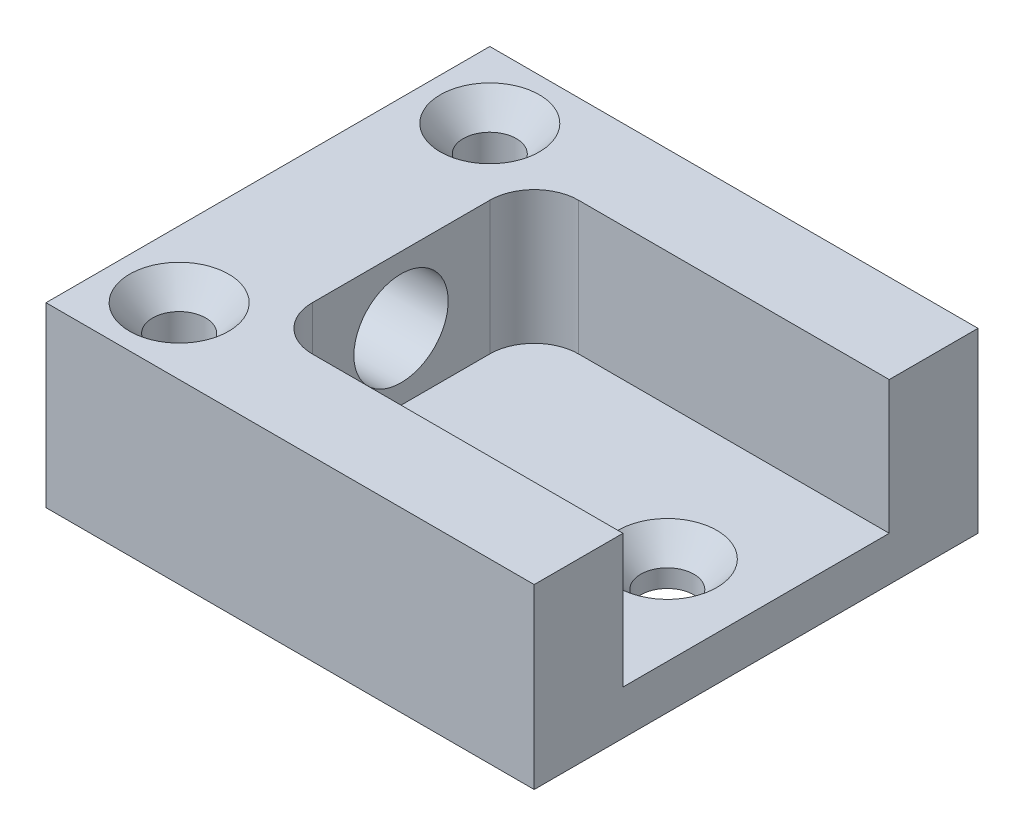
from build123d import *

# Parameters (mm, degrees)
BOSS_EXTRUDE1_DEPTH                            = 12.7
SKETCH2_W                                      = 25.4
SKETCH2_H                                      = 19.05
BOSS_EXTRUDE2_DEPTH                            = 3.175
FILLET1_R                                      = 3.175
F_17_64_0_26563_DIAMETER_HOLE1_D               = 6.747002
CSK_FOR_6_FLAT_HEAD_MACHINE_SCREW1_D           = 3.7973
CSK_FOR_6_FLAT_HEAD_MACHINE_SCREW1_DEPTH       = 16.51
CSK_FOR_6_FLAT_HEAD_MACHINE_SCREW1_CSINK_D     = 7.0866
CSK_FOR_6_FLAT_HEAD_MACHINE_SCREW1_CSINK_ANGLE = 82
CSK_FOR_6_FLAT_HEAD_MACHINE_SCREW1_TIP         = 1.140824014
CSK_FOR_6_FLAT_HEAD_MACHINE_SCREW2_D           = 3.7973
CSK_FOR_6_FLAT_HEAD_MACHINE_SCREW2_DEPTH       = 16.51
CSK_FOR_6_FLAT_HEAD_MACHINE_SCREW2_CSINK_D     = 7.0866
CSK_FOR_6_FLAT_HEAD_MACHINE_SCREW2_CSINK_ANGLE = 82
CSK_FOR_6_FLAT_HEAD_MACHINE_SCREW2_TIP         = 1.140824014


with BuildPart() as part:
    # Sketch1 → Boss-Extrude1 (new body)
    with BuildSketch(Plane(origin=(0, 0, 0), x_dir=(1, 0, 0), z_dir=(0, 1, 0))):
        Polygon((0, 15.875), (0, -15.875), (34.925, -15.875), (34.925, -9.525), (9.525, -9.525), (9.525, 9.525), (34.925, 9.525), (34.925, 15.875), align=None)
    extrude(amount=BOSS_EXTRUDE1_DEPTH)

    # Sketch2 → Boss-Extrude2 (add)
    with BuildSketch(Plane.XZ):
        with Locations((22.225, 0)):
            Rectangle(SKETCH2_W, SKETCH2_H)
    extrude(amount=-BOSS_EXTRUDE2_DEPTH)

    # Fillet1
    fillet1_edges = [part.edges().sort_by_distance(p)[0] for p in [
        (9.525, 7.9375, -9.525),
        (9.525, 7.9375, 9.525),
    ]]
    fillet(fillet1_edges, radius=FILLET1_R)

    # 17/64 (0.26563) Diameter Hole1 (through all)
    with Locations(Plane.ZY):
        with Locations((0, 7.9375)):
            Hole(F_17_64_0_26563_DIAMETER_HOLE1_D / 2)

    # CSK for #6 Flat Head Machine Screw1
    with Locations(Plane(origin=(0, 12.7, 0), x_dir=(1, 0, 0), z_dir=(0, 1, 0))):
        with Locations((4.7625, -11.1125), (4.7625, 11.1125)):
            CounterSinkHole(CSK_FOR_6_FLAT_HEAD_MACHINE_SCREW1_D / 2, CSK_FOR_6_FLAT_HEAD_MACHINE_SCREW1_CSINK_D / 2, depth=CSK_FOR_6_FLAT_HEAD_MACHINE_SCREW1_DEPTH, counter_sink_angle=CSK_FOR_6_FLAT_HEAD_MACHINE_SCREW1_CSINK_ANGLE)
            with Locations((0, 0, -(CSK_FOR_6_FLAT_HEAD_MACHINE_SCREW1_DEPTH + CSK_FOR_6_FLAT_HEAD_MACHINE_SCREW1_TIP / 2))):  # 118° drill point
                Cone(0, CSK_FOR_6_FLAT_HEAD_MACHINE_SCREW1_D / 2, CSK_FOR_6_FLAT_HEAD_MACHINE_SCREW1_TIP, mode=Mode.SUBTRACT)

    # CSK for #6 Flat Head Machine Screw2
    with Locations(Plane(origin=(0, 3.175, 0), x_dir=(1, 0, 0), z_dir=(0, 1, 0))):
        with Locations((28.575, 0)):
            CounterSinkHole(CSK_FOR_6_FLAT_HEAD_MACHINE_SCREW2_D / 2, CSK_FOR_6_FLAT_HEAD_MACHINE_SCREW2_CSINK_D / 2, depth=CSK_FOR_6_FLAT_HEAD_MACHINE_SCREW2_DEPTH, counter_sink_angle=CSK_FOR_6_FLAT_HEAD_MACHINE_SCREW2_CSINK_ANGLE)
            with Locations((0, 0, -(CSK_FOR_6_FLAT_HEAD_MACHINE_SCREW2_DEPTH + CSK_FOR_6_FLAT_HEAD_MACHINE_SCREW2_TIP / 2))):  # 118° drill point
                Cone(0, CSK_FOR_6_FLAT_HEAD_MACHINE_SCREW2_D / 2, CSK_FOR_6_FLAT_HEAD_MACHINE_SCREW2_TIP, mode=Mode.SUBTRACT)


solid = part.part
